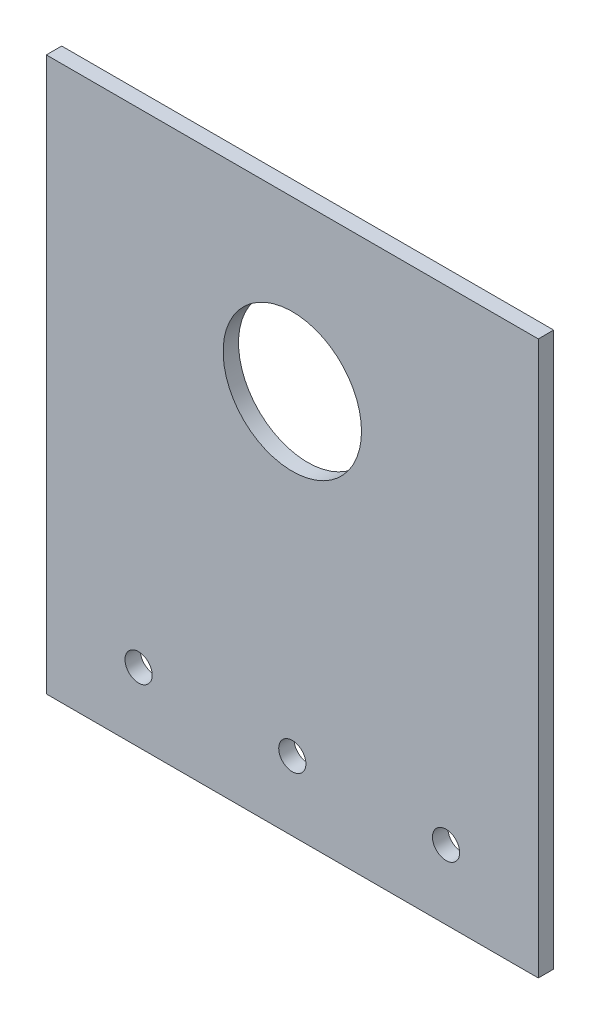
from build123d import *

# Parameters (mm, degrees)
SKETCH1_W              = 101.6
SKETCH1_H              = 114.3
BOSS_EXTRUDE1_DEPTH    = 3.175
SKETCH2_R              = 14.2875
CUT_EXTRUDE1_DEPTH     = 3.175
F_10_CLEARANCE_HOLE1_D = 5.6134


with BuildPart() as part:
    # Sketch1 → Boss-Extrude1 (new body)
    with BuildSketch(Plane.XY):
        Rectangle(SKETCH1_W, SKETCH1_H)
    extrude(amount=BOSS_EXTRUDE1_DEPTH)

    # Sketch2 → Cut-Extrude1 (cut)
    with BuildSketch(Plane.XY.offset(3.175)):
        with Locations((0, 22.352)):
            Circle(SKETCH2_R)
    extrude(amount=-CUT_EXTRUDE1_DEPTH, mode=Mode.SUBTRACT)

    # #10 Clearance Hole1 (through all)
    with Locations(Plane.XY.offset(3.175)):
        with Locations((-31.75, -42.8625), (0, -42.8625), (31.75, -42.8625)):
            Hole(F_10_CLEARANCE_HOLE1_D / 2)


solid = part.part
